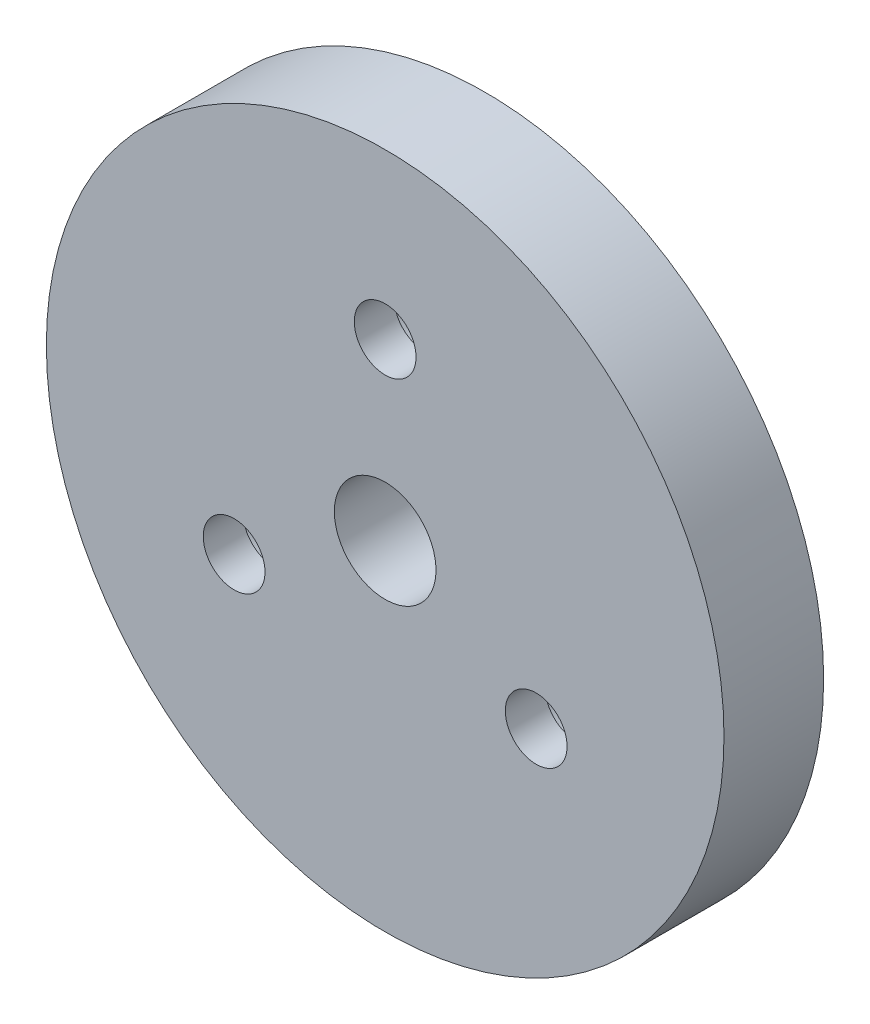
from build123d import *

# Parameters (mm, degrees)
SKETCH_1_R          = 17
EXTRUDE_1_DEPTH     = 5
SKETCH_2_R          = 2.8
CUT_EXTRUDE_1_DEPTH = 3
SKETCH_3_R          = 2.55
CUT_EXTRUDE_2_DEPTH = 6
SKETCH_7_R          = 1.55
CUT_EXTRUDE_4_DEPTH = 3


with BuildPart() as part:
    # 草图1 → 凸台-拉伸1 (new body)
    with BuildSketch(Plane.XY):
        Circle(SKETCH_1_R)
    extrude(amount=EXTRUDE_1_DEPTH)

    # 草图2 → 切除-拉伸1 (cut)
    with BuildSketch(Plane(origin=(0, 0, 0), x_dir=(-1, 0, 0), z_dir=(0, 0, -1))):
        with Locations((0, 8.75)):
            Circle(SKETCH_2_R)
        with Locations((7.577722283, -4.375)):
            Circle(SKETCH_2_R)
        with Locations((-7.577722283, -4.375)):
            Circle(SKETCH_2_R)
    extrude(amount=-CUT_EXTRUDE_1_DEPTH, mode=Mode.SUBTRACT)

    # 草图3 → 切除-拉伸2 (cut, through all)
    with BuildSketch(Plane(origin=(0, 0, 0), x_dir=(-1, 0, 0), z_dir=(0, 0, -1))):
        Circle(SKETCH_3_R)
    extrude(amount=-CUT_EXTRUDE_2_DEPTH, mode=Mode.SUBTRACT)

    # 草图7 → 切除-拉伸4 (cut, through all)
    with BuildSketch(Plane(origin=(0, 0, 3), x_dir=(-1, 0, 0), z_dir=(0, 0, -1))):
        with Locations((-7.577722283, -4.375)):
            Circle(SKETCH_7_R)
        with Locations((7.577722283, -4.375)):
            Circle(SKETCH_7_R)
        with Locations((0, 8.75)):
            Circle(SKETCH_7_R)
    extrude(amount=-CUT_EXTRUDE_4_DEPTH, mode=Mode.SUBTRACT)


solid = part.part
